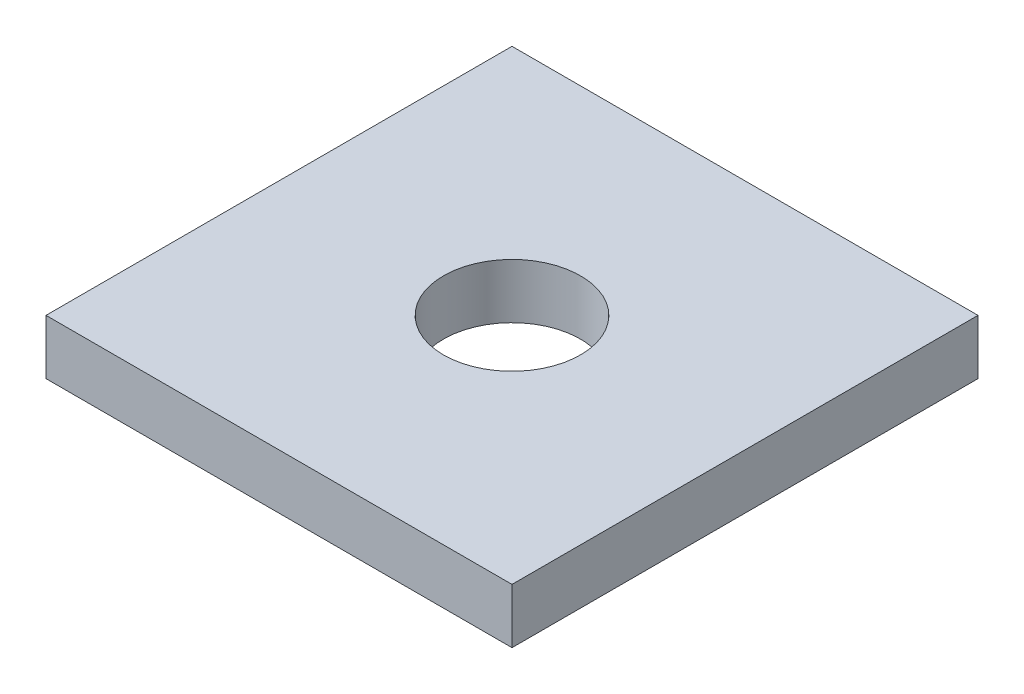
from build123d import *

# Parameters (mm, degrees)
SKETCH1_W           = 340
SKETCH1_H           = 340
BOSS_EXTRUDE1_DEPTH = 40
SKETCH2_R           = 50
CUT_EXTRUDE1_DEPTH  = 40


with BuildPart() as part:
    # Sketch1 → Boss-Extrude1 (new body)
    with BuildSketch(Plane(origin=(0, 0, 0), x_dir=(1, 0, 0), z_dir=(0, 1, 0))):
        Rectangle(SKETCH1_W, SKETCH1_H)
    extrude(amount=BOSS_EXTRUDE1_DEPTH)

    # Sketch2 → Cut-Extrude1 (cut)
    with BuildSketch(Plane(origin=(0, 40, 0), x_dir=(1, 0, 0), z_dir=(0, 1, 0))):
        Circle(SKETCH2_R)
    extrude(amount=-CUT_EXTRUDE1_DEPTH, mode=Mode.SUBTRACT)


solid = part.part
